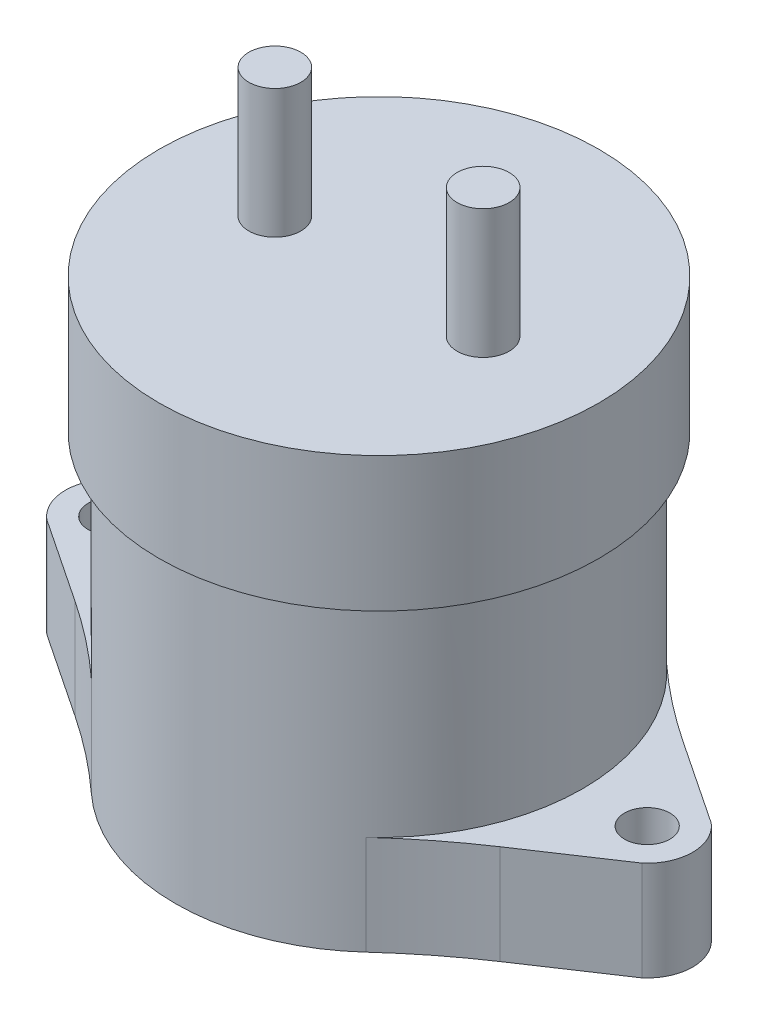
from build123d import *

# Parameters (mm, degrees)
SKETCH1_R           = 26
BOSS_EXTRUDE1_DEPTH = 14.2
SKETCH4_R           = 2.9
BOSS_EXTRUDE2_DEPTH = 12.7
SKETCH8_R           = 26
BOSS_EXTRUDE3_DEPTH = 25
SKETCH9_R           = 28.075
BOSS_EXTRUDE4_DEPTH = 17.2
SKETCH10_R          = 3.325
BOSS_EXTRUDE5_DEPTH = 16.45


with BuildPart() as part:
    # Sketch1 → Boss-Extrude1 (new body)
    with BuildSketch(Plane(origin=(0, 0, 0), x_dir=(1, 0, 0), z_dir=(0, 1, 0))):
        Circle(SKETCH1_R)
    extrude(amount=BOSS_EXTRUDE1_DEPTH)

    # Sketch4 → Boss-Extrude2 (add)
    with BuildSketch(Plane.XZ):
        with BuildLine():
            Line((27.12908409, -11.679561866), (37.990088974, -4.433027686))
            ThreePointArc((37.990088974, -4.433027686), (40.05, 0), (37.990088974, 4.433027686))
            Line((37.990088974, 4.433027686), (27.12908409, 11.679561866))
            ThreePointArc((27.12908409, 11.679561866), (22.194049101, 15.251075575), (17.545087541, 19.18775399))
            ThreePointArc((17.545087541, 19.18775399), (0, 26), (-17.545087541, 19.18775399))
            ThreePointArc((-17.545087541, 19.18775399), (-22.194049101, 15.251075575), (-27.12908409, 11.679561866))
            Line((-27.12908409, 11.679561866), (-37.990088974, 4.433027686))
            ThreePointArc((-37.990088974, 4.433027686), (-40.05, 0), (-37.990088974, -4.433027686))
            Line((-37.990088974, -4.433027686), (-27.12908409, -11.679561866))
            ThreePointArc((-27.12908409, -11.679561866), (-22.194049101, -15.251075575), (-17.545087541, -19.18775399))
            ThreePointArc((-17.545087541, -19.18775399), (0, -26), (17.545087541, -19.18775399))
            ThreePointArc((17.545087541, -19.18775399), (22.194049101, -15.251075575), (27.12908409, -11.679561866))
        make_face()
        with Locations((34.25, 0)):
            Circle(SKETCH4_R, mode=Mode.SUBTRACT)
        with Locations((-34.25, 0)):
            Circle(SKETCH4_R, mode=Mode.SUBTRACT)
    extrude(amount=-BOSS_EXTRUDE2_DEPTH)

    # Sketch8 → Boss-Extrude3 (add)
    with BuildSketch(Plane(origin=(0, 14.2, 0), x_dir=(1, 0, 0), z_dir=(0, 1, 0))):
        Circle(SKETCH8_R)
    extrude(amount=BOSS_EXTRUDE3_DEPTH)

    # Sketch9 → Boss-Extrude4 (add)
    with BuildSketch(Plane(origin=(0, 39.2, 0), x_dir=(1, 0, 0), z_dir=(0, 1, 0))):
        Circle(SKETCH9_R)
    extrude(amount=BOSS_EXTRUDE4_DEPTH)

    # Sketch10 → Boss-Extrude5 (add)
    with BuildSketch(Plane(origin=(0, 56.4, 0), x_dir=(1, 0, 0), z_dir=(0, 1, 0))):
        with Locations((13.3, 0)):
            Circle(SKETCH10_R)
        with Locations((-13.3, 0)):
            Circle(SKETCH10_R)
    extrude(amount=BOSS_EXTRUDE5_DEPTH)


solid = part.part
